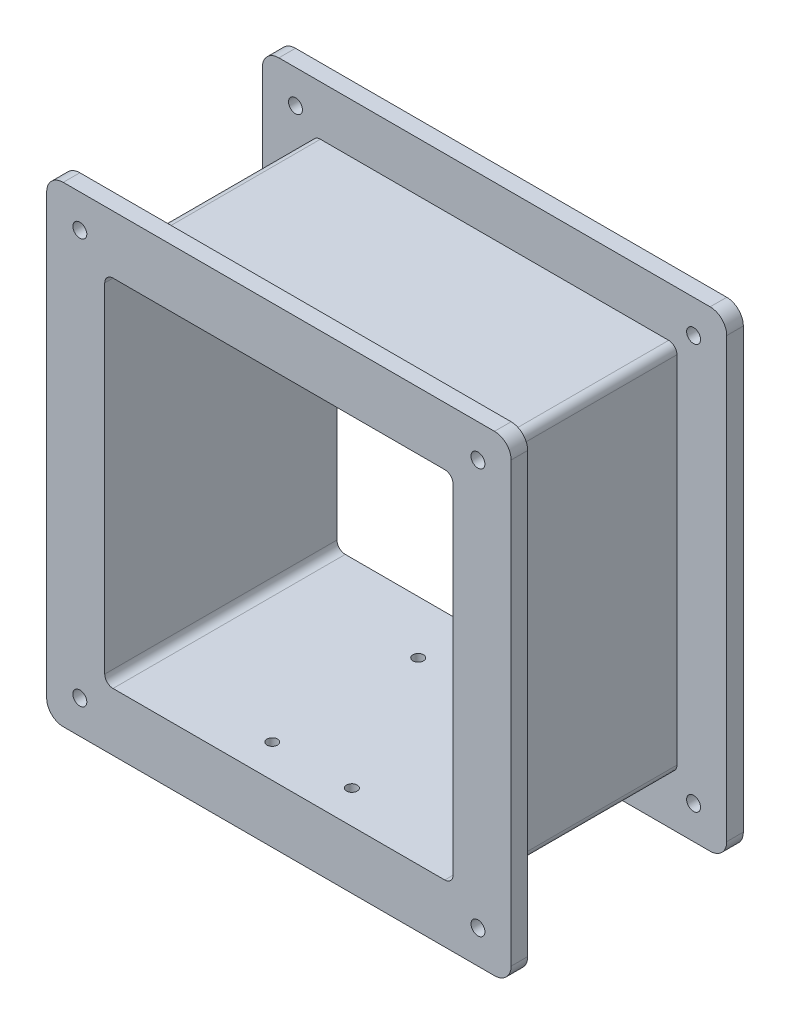
from build123d import *

# Parameters (mm, degrees)
SKETCH_4_W                  = 220
SKETCH_4_H                  = 224.25
SKETCH_4_W_2                = 210
SKETCH_4_H_2                = 214.25
EXTRUDE_7_DEPTH             = 120
SKETCH_7_W                  = 280
SKETCH_7_H                  = 284.25
SKETCH_7_W_2                = 210
SKETCH_7_H_2                = 214.25
EXTRUDE_8_DEPTH             = 10
SKETCH_8_W                  = 280
SKETCH_8_H                  = 284.25
SKETCH_8_W_2                = 210
SKETCH_8_H_2                = 214.25
EXTRUDE_9_DEPTH             = 10
FILLET_5_R                  = 5
FILLET_6_R                  = 10
HOLE_WIZARD_8_4_8_4_1_D     = 8.4
HOLE_WIZARD_6_4_6_4_1_D     = 6.4
HOLE_WIZARD_6_4_6_4_1_DEPTH = 5


with BuildPart() as part:
    # 草图4 → 凸台-拉伸7 (new body)
    with BuildSketch(Plane.XY):
        Rectangle(SKETCH_4_W, SKETCH_4_H)
        Rectangle(SKETCH_4_W_2, SKETCH_4_H_2, mode=Mode.SUBTRACT)
    extrude(amount=EXTRUDE_7_DEPTH)

    # 草图7 → 凸台-拉伸8 (add)
    with BuildSketch(Plane(origin=(0, 0, 0), x_dir=(-1, 0, 0), z_dir=(0, 0, -1))):
        Rectangle(SKETCH_7_W, SKETCH_7_H)
        Rectangle(SKETCH_7_W_2, SKETCH_7_H_2, mode=Mode.SUBTRACT)
    extrude(amount=EXTRUDE_8_DEPTH)

    # 草图8 → 凸台-拉伸9 (add)
    with BuildSketch(Plane.XY.offset(120)):
        Rectangle(SKETCH_8_W, SKETCH_8_H)
        Rectangle(SKETCH_8_W_2, SKETCH_8_H_2, mode=Mode.SUBTRACT)
    extrude(amount=EXTRUDE_9_DEPTH)

    # 圆角5
    fillet_5_edges = [part.edges().sort_by_distance(p)[0] for p in [
        (105, -107.125, 60),
        (105, 107.125, 60),
        (-105, 107.125, 60),
        (-105, -107.125, 60),
        (110, -112.125, 60),
        (-110, -112.125, 60),
        (-110, 112.125, 60),
        (110, 112.125, 60),
    ]]
    fillet(fillet_5_edges, radius=FILLET_5_R)

    # 圆角6
    fillet_6_edges = [part.edges().sort_by_distance(p)[0] for p in [
        (140, 142.125, -5),
        (140, -142.125, -5),
        (-140, -142.125, -5),
        (-140, 142.125, -5),
        (-140, 142.125, 125),
        (-140, -142.125, 125),
        (140, -142.125, 125),
        (140, 142.125, 125),
    ]]
    fillet(fillet_6_edges, radius=FILLET_6_R)

    # Ø8.4 (8.4) 直径孔1 (through all)
    with Locations(Plane(origin=(0, 0, -10), x_dir=(-1, 0, 0), z_dir=(0, 0, -1))):
        with Locations((120, -122.125), (120, 122.125), (-120, 122.125), (-120, -122.125)):
            Hole(HOLE_WIZARD_8_4_8_4_1_D / 2)

    # Ø6.4 (6.4) 直径孔1
    with Locations(Plane(origin=(0, -112.125, 0), x_dir=(-1, 0, 0), z_dir=(0, -1, 0))):
        with Locations((24, -110), (-24, -110), (-24, -22), (24, -22)):
            Hole(HOLE_WIZARD_6_4_6_4_1_D / 2, depth=HOLE_WIZARD_6_4_6_4_1_DEPTH)


solid = part.part
